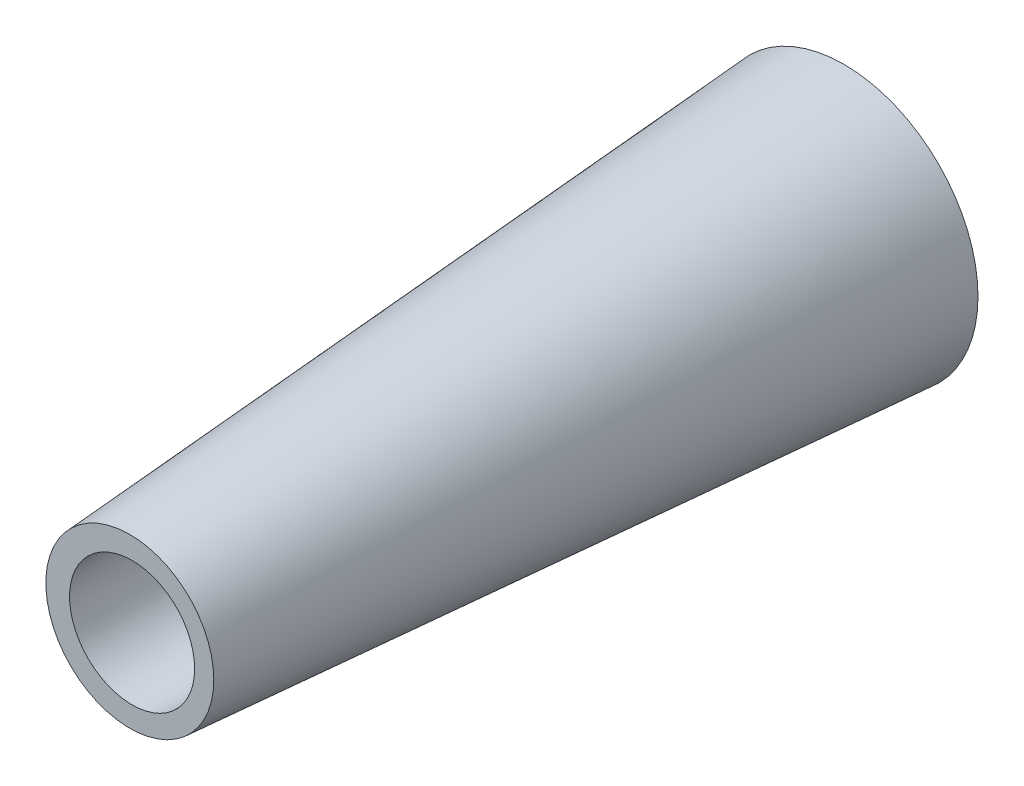
from build123d import *

# Parameters (mm, degrees)
SKIZZE1_R                       = 7.5
AUFSATZ_LINEAR_AUSTRAGEN2_DEPTH = 40
AUFSATZ_LINEAR_AUSTRAGEN2_TAPER = 4
SKIZZE3_R                       = 3.502754897
SCHNITT_LINEAR_AUSTRAGEN1_DEPTH = 35


with BuildPart() as part:
    # Skizze1 → Aufsatz-Linear austragen2 (new body)
    with BuildSketch(Plane.XY):
        Circle(SKIZZE1_R)
    extrude(amount=AUFSATZ_LINEAR_AUSTRAGEN2_DEPTH, taper=AUFSATZ_LINEAR_AUSTRAGEN2_TAPER)

    # Skizze3 → Schnitt-Linear austragen1 (cut)
    with BuildSketch(Plane.XY.offset(40)):
        with Locations((0.126687283, 0.002464382)):
            Circle(SKIZZE3_R)
    extrude(amount=-SCHNITT_LINEAR_AUSTRAGEN1_DEPTH, mode=Mode.SUBTRACT)


solid = part.part
